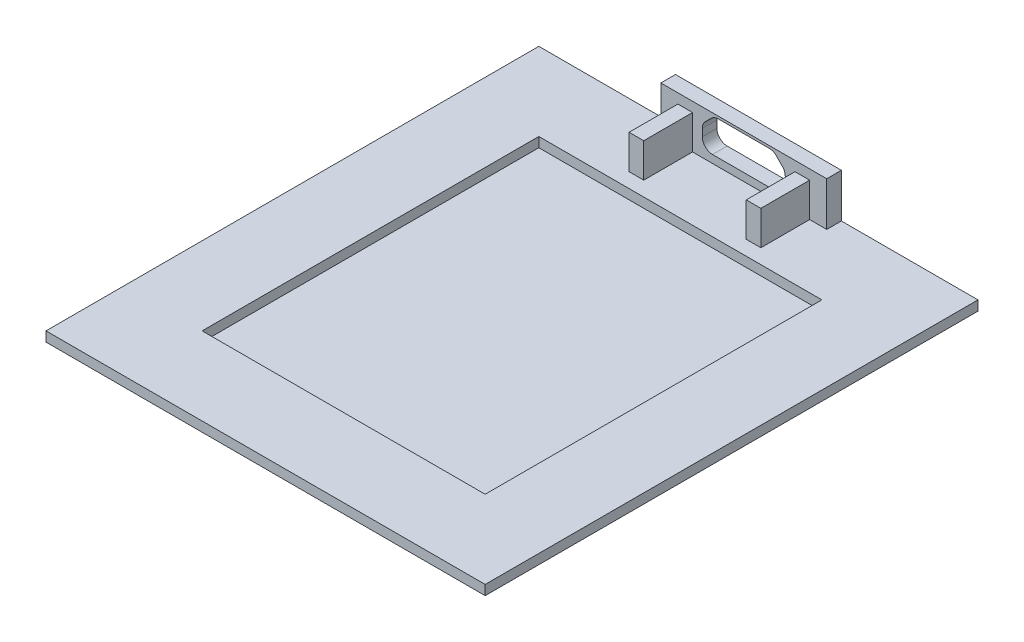
from build123d import *

# Parameters (mm, degrees)
CROQUIS1_W              = 45
CROQUIS1_H              = 50.5
SALIENTE_EXTRUIR1_DEPTH = 2
CROQUIS10_W             = 29
CROQUIS10_H             = 34.5
CORTAR_EXTRUIR5_DEPTH   = 1
CORTAR_EXTRUIR6_DEPTH   = 1
CROQUIS6_W              = 17
CROQUIS6_H              = 4.5
SALIENTE_EXTRUIR5_DEPTH = 1.5
CORTAR_EXTRUIR4_REACH   = 52.5
CROQUIS9_W              = 1.5
CROQUIS9_H              = 3.5
SALIENTE_EXTRUIR6_DEPTH = 5


with BuildPart() as part:
    # Croquis1 → Saliente-Extruir1 (new body)
    with BuildSketch(Plane(origin=(0, 0, 0), x_dir=(1, 0, 0), z_dir=(0, 1, 0))):
        with Locations((22.5, -25.25)):
            Rectangle(CROQUIS1_W, CROQUIS1_H)
    extrude(amount=SALIENTE_EXTRUIR1_DEPTH)

    # Croquis10 → Cortar-Extruir5 (cut)
    with BuildSketch(Plane(origin=(0, 2, 0), x_dir=(1, 0, 0), z_dir=(0, 1, 0))):
        with Locations((22.5, -25.25)):
            Rectangle(CROQUIS10_W, CROQUIS10_H)
    extrude(amount=-CORTAR_EXTRUIR5_DEPTH, mode=Mode.SUBTRACT)

    # Croquis11 → Cortar-Extruir6 (cut)
    with BuildSketch(Plane.XZ):
        Polygon((45, 0), (45, 50.5), (0, 50.5), (0, 0), (1, 0), (1, 49.5), (44, 49.5), (44, 0), align=None)
    extrude(amount=-CORTAR_EXTRUIR6_DEPTH, mode=Mode.SUBTRACT)

    # Croquis6 → Saliente-Extruir5 (add)
    with BuildSketch(Plane(origin=(0, 0, 0), x_dir=(-1, 0, 0), z_dir=(0, 0, -1))):
        with Locations((-22.5, 4.25)):
            Rectangle(CROQUIS6_W, CROQUIS6_H)
    extrude(amount=-SALIENTE_EXTRUIR5_DEPTH)

    # Croquis8 → Cortar-Extruir4 (cut, up to next)
    with BuildSketch(Plane(origin=(0, 0, 0), x_dir=(-1, 0, 0), z_dir=(0, 0, -1)), mode=Mode.PRIVATE) as cortar_extruir4_sk1:
        with BuildLine():
            Line((-19.16109127, 5.94246212), (-18.55753788, 5.33890873))
            ThreePointArc((-18.55753788, 5.33890873), (-18.329926491, 4.998264213), (-18.25, 4.596446609))
            Line((-18.25, 4.596446609), (-18.25, 3.85))
            ThreePointArc((-18.25, 3.85), (-18.55753788, 3.10753788), (-19.3, 2.8))
            Line((-19.3, 2.8), (-25.7, 2.8))
            ThreePointArc((-25.7, 2.8), (-26.44246212, 3.10753788), (-26.75, 3.85))
            Line((-26.75, 3.85), (-26.75, 4.596446609))
            ThreePointArc((-26.75, 4.596446609), (-26.670073509, 4.998264213), (-26.44246212, 5.33890873))
            Line((-26.44246212, 5.33890873), (-25.83890873, 5.94246212))
            ThreePointArc((-25.83890873, 5.94246212), (-25.498264213, 6.170073509), (-25.096446609, 6.25))
            Line((-25.096446609, 6.25), (-19.903553391, 6.25))
            ThreePointArc((-19.903553391, 6.25), (-19.501735787, 6.170073509), (-19.16109127, 5.94246212))
        make_face()
    cortar_extruir4_tool1 = extrude(cortar_extruir4_sk1.sketch, amount=-CORTAR_EXTRUIR4_REACH, mode=Mode.PRIVATE) & part.part
    add(cortar_extruir4_tool1.solids().sort_by_distance((22.5, 4.475322, 0))[0], mode=Mode.SUBTRACT)

    # Croquis9 → Saliente-Extruir6 (add)
    with BuildSketch(Plane.XY.offset(1.5)):
        with Locations((28.5, 3.75)):
            Rectangle(CROQUIS9_W, CROQUIS9_H)
        with Locations((16.5, 3.75)):
            Rectangle(CROQUIS9_W, CROQUIS9_H)
    extrude(amount=SALIENTE_EXTRUIR6_DEPTH)


solid = part.part
